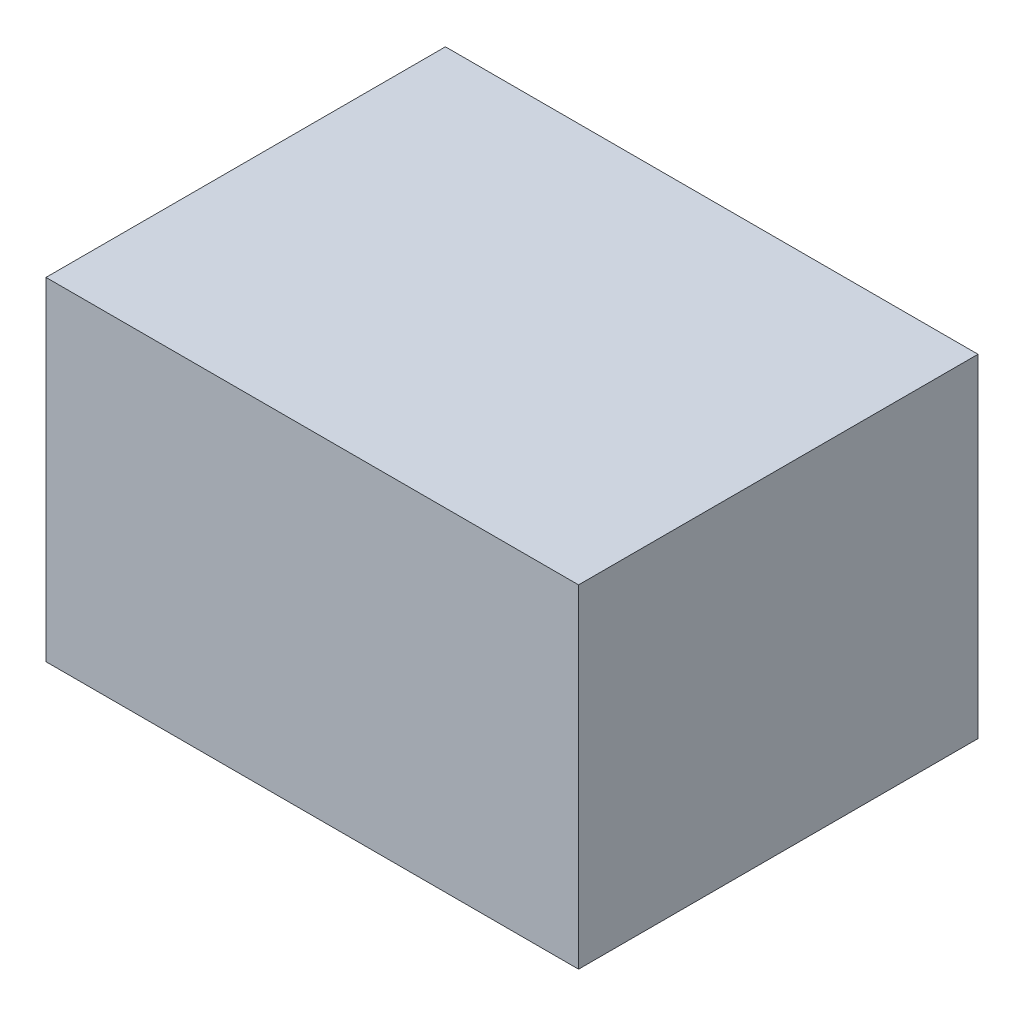
from build123d import *

# Parameters (mm, degrees)
SKETCH1_W           = 800
SKETCH1_H           = 600
BOSS_EXTRUDE1_DEPTH = 500


with BuildPart() as part:
    # Sketch1 → Boss-Extrude1 (new body)
    with BuildSketch(Plane(origin=(0, 0, 0), x_dir=(1, 0, 0), z_dir=(0, 1, 0))):
        with Locations((400, 300)):
            Rectangle(SKETCH1_W, SKETCH1_H)
    extrude(amount=BOSS_EXTRUDE1_DEPTH)


solid = part.part
